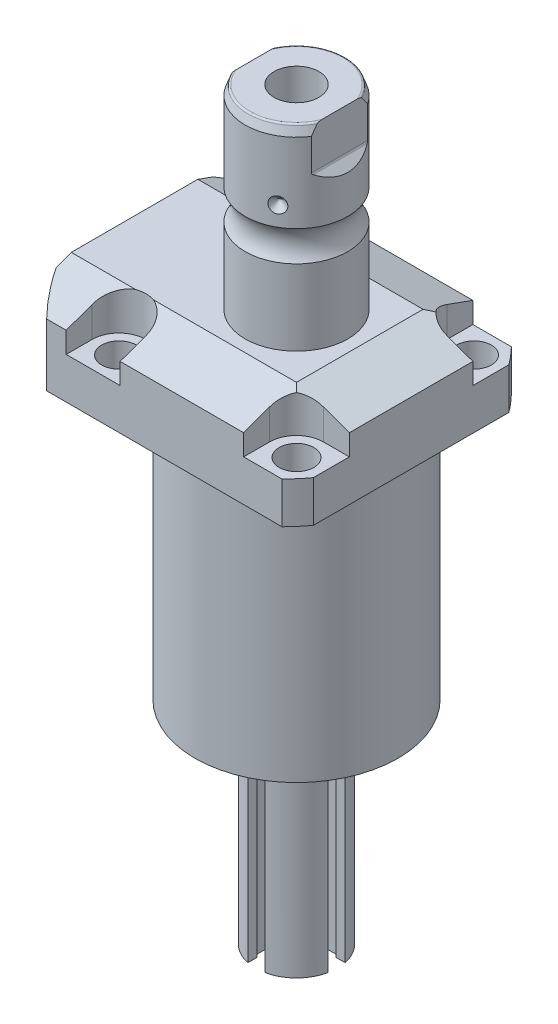
from build123d import *

# Parameters (mm, degrees)
SKETCH1_W                   = 70.866
SKETCH1_H                   = 85.496
EXTRUDE1_DEPTH              = 104.521
SKETCH2_OUTSIDE_W           = 117.996
SKETCH2_OUTSIDE_H           = 103.366
SKETCH2_OUTSIDE_R           = 50.8
CUT_EXTRUDE1_DEPTH          = 105.521
SKETCH3_W                   = 45.1992
SKETCH3_H                   = 79.502
FILLET1_R                   = 0.381
CUT_EXTRUDE2_DEPTH          = 12.243
CUT_EXTRUDE9_START          = -51.063
CUT_EXTRUDE9_DEPTH          = 87.496
CUT_EXTRUDE7_DEPTH          = 36.433
CUT_EXTRUDE7_DEPTH_BACK     = 36.433
SKETCH10_R                  = 1.1811
SKETCH17_W                  = 5.3594
SKETCH17_H                  = 12.776
HOLE1_AT_2_COUNT            = 2
HOLE1_AT_2_PITCH            = 54.864
HOLE1_AT_3_COUNT            = 2
HOLE1_AT_3_PITCH            = 77.589412886
HOLE1_AT_4_COUNT            = 2
HOLE1_AT_4_PITCH            = 54.864
CHAMFER1_SIZE               = 0.635
FILLET2_R                   = 0.635
CIRPATTERN1_COUNT           = 3
CUT_EXTRUDE10_DEPTH         = 36.433
CUT_EXTRUDE10_DEPTH_BACK    = 36.433
SKETCH31_R                  = 1.727203454
SKETCH31_R_2                = 1.727
CUT_EXTRUDE11_DEPTH         = 82.042005
SKETCH32_R                  = 2.705
SKETCH32_R_2                = 2.70510541
EXTRUDE2_DEPTH              = 2.946405893
CUT_EXTRUDE12_DEPTH         = 2.032004064
CUT_EXTRUDE13_DEPTH         = 6.477012954
SKETCH35_W                  = 6.98501397
SKETCH35_H                  = 54.864109728
CUT_EXTRUDE14_DEPTH         = 3.302006604
CIRPATTERN2_COUNT           = 2
CIRPATTERN2_ANGLE           = 90
CIRPATTERN2_COPY_1_DEPTH    = 6.477012954
CIRPATTERN2_COPY_2_SKETCH_W = 6.98501397
CIRPATTERN2_COPY_2_SKETCH_H = 54.864109728
CIRPATTERN2_COPY_2_DEPTH    = 3.302006604


with BuildPart() as part:
    # Sketch1 → Extrude1 (new body)
    with BuildSketch(Plane(origin=(0, 0, 0), x_dir=(0, 0, 1), z_dir=(0, -1, 0))):
        with Locations((0, 7.315)):
            Rectangle(SKETCH1_W, SKETCH1_H)
    extrude(amount=-EXTRUDE1_DEPTH)

    # Sketch2 outside → Cut-Extrude1 (cut, through all)
    with BuildSketch(Plane.XZ):
        with Locations((-7.315, 0)):
            Rectangle(SKETCH2_OUTSIDE_W, SKETCH2_OUTSIDE_H)
        with Locations((-5.4102, 0)):
            Circle(SKETCH2_OUTSIDE_R, mode=Mode.SUBTRACT)
    extrude(amount=-CUT_EXTRUDE1_DEPTH, mode=Mode.SUBTRACT)

    # Sketch3 → Cut-Revolve1 (revolve, cut)
    with BuildSketch(Plane(origin=(0, 0, 0), x_dir=(0, 0, -1), z_dir=(1, 0, 0))):
        with Locations((53.9941, 39.751)):
            Rectangle(SKETCH3_W, SKETCH3_H)
    revolve(axis=Axis((0, -93.345, 0), (0, 1, 0)), mode=Mode.SUBTRACT)

    # Fillet1
    fillet1_edges = [part.edges().sort_by_distance(p)[0] for p in [
        (0, 79.502, 31.3945),
    ]]
    fillet(fillet1_edges, radius=FILLET1_R)

    # Sketch4 → Cut-Extrude2 (cut)
    with BuildSketch(Plane(origin=(0, 104.521, 0), x_dir=(-1, 0, 0), z_dir=(0, 1, 0))):
        with BuildLine():
            Line((-19.1008, -35.433), (-19.1008, -27.432))
            ThreePointArc((-19.1008, -27.432), (-21.540951985, -21.540951985), (-27.432, -19.1008))
            Line((-27.432, -19.1008), (-35.433, -19.1008))
            Line((-35.433, -19.1008), (-35.433, -35.433))
            Line((-35.433, -35.433), (-19.1008, -35.433))
        make_face()
        with BuildLine():
            Line((35.7632, -35.433), (19.1008, -35.433))
            Line((19.1008, -35.433), (19.1008, -27.432))
            ThreePointArc((19.1008, -27.432), (27.432, -19.1008), (35.7632, -27.432))
            Line((35.7632, -27.432), (35.7632, -35.433))
        make_face()
        with BuildLine():
            Line((19.1008, 35.433), (19.1008, 27.432))
            ThreePointArc((19.1008, 27.432), (27.432, 19.1008), (35.7632, 27.432))
            Line((35.7632, 27.432), (35.7632, 35.433))
            Line((35.7632, 35.433), (19.1008, 35.433))
        make_face()
        with BuildLine():
            Line((-27.432, 19.1008), (-35.433, 19.1008))
            Line((-35.433, 19.1008), (-35.433, 35.433))
            Line((-35.433, 35.433), (-19.1008, 35.433))
            Line((-19.1008, 35.433), (-19.1008, 27.432))
            ThreePointArc((-19.1008, 27.432), (-21.540951985, 21.540951985), (-27.432, 19.1008))
        make_face()
    extrude(amount=-CUT_EXTRUDE2_DEPTH, mode=Mode.SUBTRACT)

    # Sketch5 → Cut-Extrude9 (cut)
    with BuildSketch(Plane(origin=(0, 0, 0), x_dir=(0, 0, -1), z_dir=(1, 0, 0)).offset(CUT_EXTRUDE9_START)):
        Polygon((-19.558, 104.521), (-35.433, 98.742972531), (-35.433, 104.521), align=None)
    cut_extrude9 = extrude(amount=CUT_EXTRUDE9_DEPTH, mode=Mode.SUBTRACT)

    # Mirror1: Cut-Extrude9 across plane
    add(cut_extrude9.mirror(Plane.XY), mode=Mode.SUBTRACT)

    # Sketch9 → Cut-Extrude7 (cut, two sides)
    with BuildSketch(Plane.XY) as cut_extrude7_sk:
        Polygon((19.558, 104.521), (35.433, 98.742972531), (35.433, 104.521), align=None)
    extrude(amount=CUT_EXTRUDE7_DEPTH, mode=Mode.SUBTRACT)
    extrude(cut_extrude7_sk.sketch, amount=-CUT_EXTRUDE7_DEPTH_BACK, mode=Mode.SUBTRACT)

    # Sketch20 → Cut-Revolve4 (revolve, cut)
    with BuildSketch(Plane(origin=(-35.0774, 88.9, -18.1102), x_dir=(0, 1, 0), z_dir=(1, 0, 0)), mode=Mode.PRIVATE) as cut_revolve4_sk:
        Polygon((-9.398, 38.3413), (-7.9502, 38.3413), (-7.9502, 35.8902), (-6.9342, 35.8902), (-6.9342, 33.8836), (4.0386, 33.8836), (4.0386, 32.639), (-9.398, 32.639), align=None)
    cut_revolve4 = revolve(cut_revolve4_sk.sketch.rotate(Axis((-35.0774, 81.620304954, 14.5288), (0, 1, 0)), 180), axis=Axis((-35.0774, 81.620304954, 14.5288), (0, 1, 0)), mode=Mode.SUBTRACT)  # turned: the seam where the file's is

    # Mirror10: Cut-Revolve4 across plane
    add(cut_revolve4.mirror(Plane.XY), mode=Mode.SUBTRACT)

    # Sketch15 → Revolve3 (revolve)
    with BuildSketch(Plane(origin=(0, 0, 0), x_dir=(0, 0, -1), z_dir=(1, 0, 0)), mode=Mode.PRIVATE) as revolve3_sk:
        with BuildLine():
            Line((0, 104.521), (15.875, 104.521))
            Line((15.875, 104.521), (15.875, 127.90590643))
            ThreePointArc((15.875, 127.90590643), (14.3256, 132.613), (15.875, 137.32009357))
            Line((15.875, 137.32009357), (15.875, 161.79799416))
            Line((15.875, 161.79799416), (14.81184082, 164.719))
            Line((14.81184082, 164.719), (0, 164.719))
            Line((0, 164.719), (0, 104.521))
        make_face()
    revolve(revolve3_sk.sketch.rotate(Axis((0, 250.290824608, 0), (0, -1, 0)), 180), axis=Axis((0, 250.290824608, 0), (0, -1, 0)))  # turned: the seam where the file's is

    # Sketch17 → Hole1 (revolve, cut)
    with BuildSketch(Plane(origin=(27.432, 92.278, -27.432), x_dir=(0, 0, 1), z_dir=(1, 0, 0))):
        with Locations((2.6797, 6.388)):
            Rectangle(SKETCH17_W, SKETCH17_H)
    hole1 = revolve(axis=Axis((27.432, -17.722, -27.432), (0, 1, 0)), mode=Mode.SUBTRACT)

    # Hole1 at 2: Hole1 ×2
    with Locations(*[(0, 0, i * HOLE1_AT_2_PITCH) for i in range(1, HOLE1_AT_2_COUNT)]):
        add(hole1, mode=Mode.SUBTRACT)

    # Hole1 at 3: Hole1 ×2
    with Locations(*[Vector(-0.707106781, 0, 0.707106781) * (i * HOLE1_AT_3_PITCH) for i in range(1, HOLE1_AT_3_COUNT)]):
        add(hole1, mode=Mode.SUBTRACT)

    # Hole1 at 4: Hole1 ×2
    with Locations(*[(-i * HOLE1_AT_4_PITCH, 0, 0) for i in range(1, HOLE1_AT_4_COUNT)]):
        add(hole1, mode=Mode.SUBTRACT)

    # Chamfer1
    chamfer1_edges = [part.edges().sort_by_distance(p)[0] for p in [
        (-35.0774, 81.9658, 15.7734),
        (-35.0774, 81.9658, -15.7734),
    ]]
    chamfer(chamfer1_edges, length=CHAMFER1_SIZE)

    # Sketch21 → Cut-Revolve5 (revolve, cut)
    with BuildSketch(Plane.XZ.offset(-92.5068)):
        Polygon((-50.063, -1.9304), (-49.809, -1.9304), (-49.809, -6.3246), (-49.0978, -7.0358), (-35.6358, -7.0358), (-35.6358, -12.9794), (-50.063, -12.9794), align=None)
    cut_revolve5 = revolve(axis=Axis((-57.549532301, 92.5068, -12.9794), (1, 0, 0)), mode=Mode.SUBTRACT)

    # Mirror13: Cut-Revolve5 across plane
    add(cut_revolve5.mirror(Plane.XY), mode=Mode.SUBTRACT)

    # Fillet2
    fillet2_edges = [part.edges().sort_by_distance(p)[0] for p in [
        (0, 164.719, -14.81184082),
    ]]
    fillet(fillet2_edges, radius=FILLET2_R)

    # Sketch26 → Cut-Revolve7 (revolve, cut)
    with BuildSketch(Plane.XY, mode=Mode.PRIVATE) as cut_revolve7_sk:
        Polygon((-15.875, 145.714), (-13.462, 143.301), (-15.875, 143.301), align=None)
    cut_revolve7 = revolve(cut_revolve7_sk.sketch.rotate(Axis((-39.772000707, 143.301, 0), (1, 0, 0)), 90), axis=Axis((-39.772000707, 143.301, 0), (1, 0, 0)), mode=Mode.SUBTRACT)  # turned: the seam where the file's is

    # CirPattern1: Cut-Revolve7 ×3 about axis
    cirpattern1_axis = Axis((0, 250.290824608, 0), (0, 1, 0))
    for i in range(1, CIRPATTERN1_COUNT):
        add(cut_revolve7.rotate(cirpattern1_axis, i * 360 / CIRPATTERN1_COUNT), mode=Mode.SUBTRACT)

    # Sketch27 → Hole2 (revolve, cut)
    with BuildSketch(Plane(origin=(0, 164.719, 0), x_dir=(0, 0, 1), z_dir=(1, 0, 0))):
        Polygon((0, 0), (0, 29.566487704), (6.9342, 25.4), (6.9342, 0), align=None)
    revolve(axis=Axis((0, 168.963199587, 0), (0, -1, 0)), mode=Mode.SUBTRACT)

    # Sketch29 → Cut-Extrude10 (cut, two sides)
    with BuildSketch(Plane.XY) as cut_extrude10_sk:
        with BuildLine():
            Line((13.284, 164.719), (13.284, 152.019))
            ThreePointArc((13.284, 152.019), (13.342003912, 151.727394643), (13.507185078, 151.480183558))
            Line((13.507185078, 151.480183558), (15.875, 149.112368636))
            Line((15.875, 149.112368636), (15.875, 164.719))
            Line((15.875, 164.719), (13.284, 164.719))
        make_face()
        with BuildLine():
            Line((-15.875, 164.719), (-13.284, 164.719))
            Line((-13.284, 164.719), (-13.284, 152.019))
            ThreePointArc((-13.284, 152.019), (-13.342003912, 151.727394643), (-13.507185078, 151.480183558))
            Line((-13.507185078, 151.480183558), (-15.875, 149.112368636))
            Line((-15.875, 149.112368636), (-15.875, 164.719))
        make_face()
    extrude(amount=CUT_EXTRUDE10_DEPTH, mode=Mode.SUBTRACT)
    extrude(cut_extrude10_sk.sketch, amount=-CUT_EXTRUDE10_DEPTH_BACK, mode=Mode.SUBTRACT)

    # Sketch30 → Revolve5 (revolve)
    with BuildSketch(Plane.XY, mode=Mode.PRIVATE) as revolve5_sk:
        Polygon((0, 0), (22.22504445, 0), (22.22504445, -2.54000508), (12.7000254, -2.54000508), (12.7000254, -65.532131064), (0, -65.532131064), align=None)
    revolve(revolve5_sk.sketch.rotate(Axis((0, -963.130914712, 0), (0, 1, 0)), 270), axis=Axis((0, -963.130914712, 0), (0, 1, 0)))  # turned: the seam where the file's is

    # Sketch31 → Cut-Extrude11 (cut)
    with BuildSketch(Plane.XZ.offset(2.54000508)):
        with Locations((19.431038862, 0)):
            Circle(SKETCH31_R)
        with Locations((16.827773276, 9.715519431)):
            Circle(SKETCH31_R_2)
        with Locations((9.715519431, 16.827773276)):
            Circle(SKETCH31_R_2)
        with Locations((0, 19.431038862)):
            Circle(SKETCH31_R_2)
        with Locations(Location((-9.715519431, 16.827773276, 0), (0, 0, 90))):  # turned: the seam where the file's is
            Circle(SKETCH31_R_2)
        with Locations(Location((-16.827773276, 9.715519431, 0), (0, 0, 90))):  # turned: the seam where the file's is
            Circle(SKETCH31_R_2)
        with Locations(Location((-19.431038862, 0, 0), (0, 0, 90))):  # turned: the seam where the file's is
            Circle(SKETCH31_R)
        with Locations(Location((16.827773276, -9.715519431, 0), (0, 0, 90))):  # turned: the seam where the file's is
            Circle(SKETCH31_R_2)
        with Locations(Location((9.715519431, -16.827773276, 0), (0, 0, 90))):  # turned: the seam where the file's is
            Circle(SKETCH31_R_2)
        with Locations(Location((0, -19.431038862, 0), (0, 0, 90))):  # turned: the seam where the file's is
            Circle(SKETCH31_R_2)
        with Locations((-9.715519431, -16.827773276)):
            Circle(SKETCH31_R_2)
        with Locations((-16.827773276, -9.715519431)):
            Circle(SKETCH31_R_2)
    extrude(amount=-CUT_EXTRUDE11_DEPTH, mode=Mode.SUBTRACT)

    # Sketch32 → Extrude2 (add)
    with BuildSketch(Plane.XZ.offset(2.54000508)):
        with Locations((19.431038862, 0)):
            Circle(SKETCH32_R)
        with Locations((-9.715519431, 16.827773276)):
            Circle(SKETCH32_R)
        with Locations((-9.715519431, -16.827773276)):
            Circle(SKETCH32_R_2)
    extrude(amount=EXTRUDE2_DEPTH)

    # Sketch33 → Cut-Extrude12 (cut)
    with BuildSketch(Plane.XZ.offset(5.486410973)):
        Polygon((-9.033704626, -18.099961118), (-8.272865039, -16.873398255), (-8.954679844, -15.601210414), (-10.397334236, -15.555585435), (-11.158173823, -16.782148298), (-10.476359018, -18.054336139), align=None)
        Polygon((20.279147066, -1.167923717), (20.866544572, 0.150521391), (20.018436369, 1.318445108), (18.582930659, 1.167923717), (17.995533152, -0.150521391), (18.843641355, -1.318445108), align=None)
        Polygon((-9.715519431, 15.384397604), (-8.465519431, 16.10608544), (-8.465519431, 17.549461113), (-9.715519431, 18.271148949), (-10.965519431, 17.549461113), (-10.965519431, 16.10608544), align=None)
    extrude(amount=-CUT_EXTRUDE12_DEPTH, mode=Mode.SUBTRACT)

    # Sketch34 → Cut-Extrude13 (cut)
    with BuildSketch(Plane(origin=(0, -34.036068072, 12.7000254), x_dir=(-1, 0, 0), z_dir=(0, 0, 1))):
        with BuildLine():
            Line((-2.641605283, -21.083429092), (-2.641605283, 31.496062992))
            Line((-2.641605283, 31.496062992), (2.641605283, 31.496062992))
            Line((2.641605283, 31.496062992), (2.641605283, -21.083429092))
            ThreePointArc((2.641605283, -21.083429092), (0, -26.860546736), (-2.641605283, -21.083429092))
        make_face()
    cut_extrude13 = extrude(amount=-CUT_EXTRUDE13_DEPTH, mode=Mode.SUBTRACT)

    # Sketch35 → Cut-Extrude14 (cut)
    with BuildSketch(Plane.XY.offset(6.223012446)):
        with Locations((0, -38.1000762)):
            Rectangle(SKETCH35_W, SKETCH35_H)
    cut_extrude14 = extrude(amount=CUT_EXTRUDE14_DEPTH, mode=Mode.SUBTRACT)

    # Mirror14: Cut-Extrude13, Cut-Extrude14 across plane
    add(cut_extrude13.mirror(Plane.XY), mode=Mode.SUBTRACT)
    add(cut_extrude14.mirror(Plane.XY), mode=Mode.SUBTRACT)

    # CirPattern2: Cut-Extrude13, Cut-Extrude14 ×2 about axis
    cirpattern2_axis = Axis((0, 0, 0), (0, -1, 0))
    add([cut_extrude13.rotate(cirpattern2_axis, i * CIRPATTERN2_ANGLE / (CIRPATTERN2_COUNT - 1)) for i in range(1, CIRPATTERN2_COUNT)], mode=Mode.SUBTRACT)
    add([cut_extrude14.rotate(cirpattern2_axis, i * CIRPATTERN2_ANGLE / (CIRPATTERN2_COUNT - 1)) for i in range(1, CIRPATTERN2_COUNT)], mode=Mode.SUBTRACT)

    # CirPattern2 copy 1 sketch → CirPattern2 copy 1 (cut)
    with BuildSketch(Plane(origin=(12.7000254, -34.036068072, 0), x_dir=(0, 0, -1), z_dir=(1, 0, 0))):
        with BuildLine():
            Line((-2.641605283, 21.083429092), (-2.641605283, -31.496062992))
            Line((-2.641605283, -31.496062992), (2.641605283, -31.496062992))
            Line((2.641605283, -31.496062992), (2.641605283, 21.083429092))
            ThreePointArc((2.641605283, 21.083429092), (0, 26.860546736), (-2.641605283, 21.083429092))
        make_face()
    extrude(amount=-CIRPATTERN2_COPY_1_DEPTH, mode=Mode.SUBTRACT)

    # CirPattern2 copy 2 sketch → CirPattern2 copy 2 (cut)
    with BuildSketch(Plane(origin=(6.223012446, 0, 0), x_dir=(0, 0, 1), z_dir=(1, 0, 0))):
        with Locations((0, 38.1000762)):
            Rectangle(CIRPATTERN2_COPY_2_SKETCH_W, CIRPATTERN2_COPY_2_SKETCH_H)
    extrude(amount=CIRPATTERN2_COPY_2_DEPTH, mode=Mode.SUBTRACT)


with BuildPart() as body_2:
    # Sketch10 → Revolve4 (revolve)
    with BuildSketch(Plane(origin=(-35.0774, 88.9, -18.1102), x_dir=(0, 1, 0), z_dir=(1, 0, 0))):
        with Locations((-9.1313, 8.1026)):
            Circle(SKETCH10_R)
    revolve(axis=Axis((-35.0774, 87.86749, -14.5288), (0, 1, 0)))


with BuildPart() as body_3:
    # Mirror12: mirrored copy
    add(body_2.part.mirror(Plane.XY))


solid = Compound([part.part, body_2.part, body_3.part])
